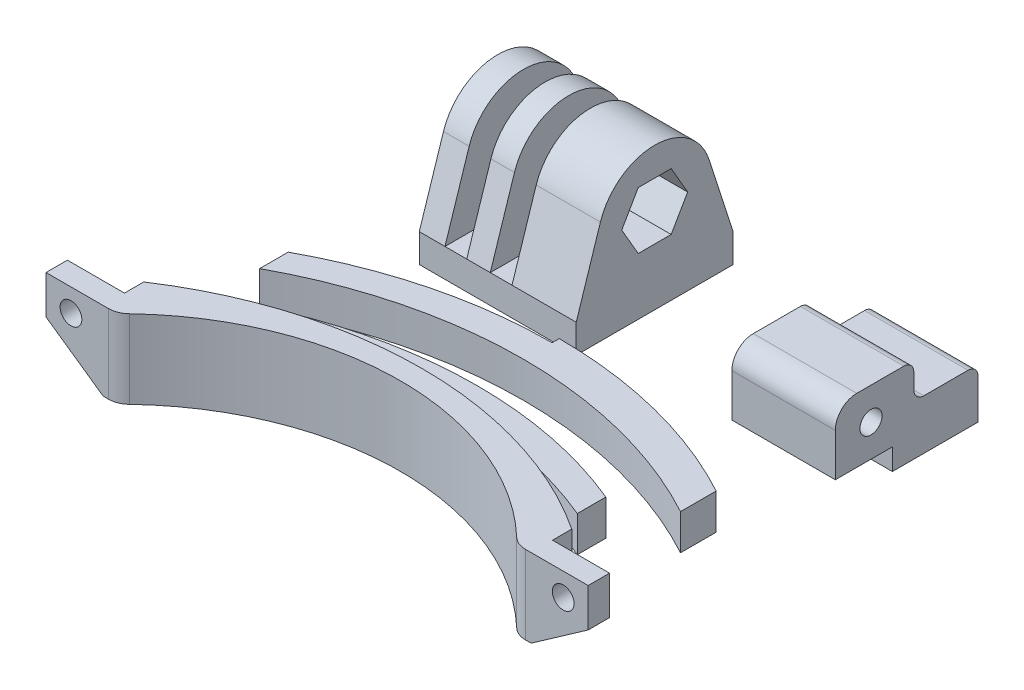
from build123d import *

# Parameters (mm, degrees)
BOSS_EXTRUDE1_DEPTH = 11
CUT_EXTRUDE1_REACH  = 16.7
SKETCH2_R           = 1.525
CUT_EXTRUDE12_REACH = 16.7
BOSS_EXTRUDE2_DEPTH = 5
CUT_EXTRUDE11_DEPTH = 5
BOSS_EXTRUDE3_DEPTH = 5
SKETCH10_W          = 14.5
SKETCH10_H          = 20
BOSS_EXTRUDE6_DEPTH = 12
SKETCH11_W          = 8
SKETCH11_H          = 3
CUT_EXTRUDE5_DEPTH  = 14.5
SKETCH12_R          = 1.55
CUT_EXTRUDE6_DEPTH  = 14.5
SKETCH13_W          = 22
SKETCH13_H          = 22
BOSS_EXTRUDE7_DEPTH = 4
SKETCH14_W          = 22
SKETCH14_H          = 18
SKETCH14_R          = 2.55
BOSS_EXTRUDE8_DEPTH = 22
CUT_EXTRUDE7_DEPTH  = 22
CUT_EXTRUDE8_START  = -20
SKETCH17_W          = 3.05
SKETCH17_H          = 22
CUT_EXTRUDE8_DEPTH  = 16
CUT_EXTRUDE9_DEPTH  = 7


with BuildPart() as part:
    # Sketch1 → Boss-Extrude1 (new body)
    with BuildSketch(Plane(origin=(0, 0, 0), x_dir=(1, 0, 0), z_dir=(0, 1, 0))):
        with BuildLine():
            Line((-30, 0), (-30, -2.7))
            Line((-30, -2.7), (-38, -2.7))
            Line((-38, -2.7), (-38, -5.7))
            Line((-38, -5.7), (-29.226700122, -5.7))
            ThreePointArc((-29.226700122, -5.7), (-28.111762502, -5.485123714), (-27.156540652, -4.87127607))
            ThreePointArc((-27.156540652, -4.87127607), (0, 6), (27.156540652, -4.87127607))
            ThreePointArc((27.156540652, -4.87127607), (28.111762502, -5.485123714), (29.226700122, -5.7))
            Line((29.226700122, -5.7), (38, -5.7))
            Line((38, -5.7), (38, -2.7))
            Line((38, -2.7), (30, -2.7))
            Line((30, -2.7), (30, 0))
            ThreePointArc((30, 0), (0, 9), (-30, 0))
        make_face()
    extrude(amount=BOSS_EXTRUDE1_DEPTH)

    # Sketch2 → Cut-Extrude1 (cut, up to next)
    with BuildSketch(Plane.XY.offset(5.7), mode=Mode.PRIVATE) as cut_extrude1_sk1:
        with Locations((-34.5, 7.8)):
            Circle(SKETCH2_R)
    cut_extrude1_tool1 = extrude(cut_extrude1_sk1.sketch, amount=-CUT_EXTRUDE1_REACH, mode=Mode.PRIVATE) & part.part
    add(cut_extrude1_tool1.solids().sort_by_distance((-34.5, 7.8, 5.7))[0], mode=Mode.SUBTRACT)
    # Sketch2 → Cut-Extrude1 (cut, up to next)
    with BuildSketch(Plane.XY.offset(5.7), mode=Mode.PRIVATE) as cut_extrude1_sk2:
        with Locations((34.5, 7.8)):
            Circle(SKETCH2_R)
    cut_extrude1_tool2 = extrude(cut_extrude1_sk2.sketch, amount=-CUT_EXTRUDE1_REACH, mode=Mode.PRIVATE) & part.part
    add(cut_extrude1_tool2.solids().sort_by_distance((34.5, 7.8, 5.7))[0], mode=Mode.SUBTRACT)

    # Sketch20 → Cut-Extrude12 (cut, up to next)
    with BuildSketch(Plane.XY.offset(5.7), mode=Mode.PRIVATE) as cut_extrude12_sk1:
        Polygon((-38, 5.6), (-30, 0), (-38, 0), align=None)
    cut_extrude12_tool1 = extrude(cut_extrude12_sk1.sketch, amount=-CUT_EXTRUDE12_REACH, mode=Mode.PRIVATE) & part.part
    add(cut_extrude12_tool1.solids().sort_by_distance((-35.333333, 1.866667, 5.7))[0], mode=Mode.SUBTRACT)
    # Sketch20 → Cut-Extrude12 (cut, up to next)
    with BuildSketch(Plane.XY.offset(5.7), mode=Mode.PRIVATE) as cut_extrude12_sk2:
        Polygon((38, 0), (30, 0), (38, 5.6), align=None)
    cut_extrude12_tool2 = extrude(cut_extrude12_sk2.sketch, amount=-CUT_EXTRUDE12_REACH, mode=Mode.PRIVATE) & part.part
    add(cut_extrude12_tool2.solids().sort_by_distance((35.333333, 1.866667, 5.7))[0], mode=Mode.SUBTRACT)


with BuildPart() as body_2:
    # Sketch3 → Boss-Extrude2 (new body)
    with BuildSketch(Plane(origin=(0, 0, 0), x_dir=(1, 0, 0), z_dir=(0, 1, 0))):
        with BuildLine():
            Line((-29.5, 8.785778647), (-29.5, 4.785778647))
            ThreePointArc((-29.5, 4.785778647), (0, 12.785778647), (29.5, 4.785778647))
            Line((29.5, 4.785778647), (29.5, 8.785778647))
            ThreePointArc((29.5, 8.785778647), (0, 16.785778647), (-29.5, 8.785778647))
        make_face()
    extrude(amount=BOSS_EXTRUDE2_DEPTH)

    # Sketch21 → Cut-Extrude11 (cut)
    with BuildSketch(Plane(origin=(0, 5, 0), x_dir=(1, 0, 0), z_dir=(0, 1, 0))):
        with BuildLine():
            ThreePointArc((-29.5, 4.785778647), (-26.058521382, 6.648560725), (-22.5, 8.276644791))
            Line((-22.5, 8.276644791), (-22.5, 12.276644791))
            ThreePointArc((-22.5, 12.276644791), (-26.058521382, 10.648560725), (-29.5, 8.785778647))
            Line((-29.5, 8.785778647), (-29.5, 4.785778647))
        make_face()
        with BuildLine():
            Line((22.5, 12.276644791), (22.5, 8.276644791))
            ThreePointArc((22.5, 8.276644791), (26.058521382, 6.648560725), (29.5, 4.785778647))
            Line((29.5, 4.785778647), (29.5, 8.785778647))
            ThreePointArc((29.5, 8.785778647), (26.058521382, 10.648560725), (22.5, 12.276644791))
        make_face()
    extrude(amount=-CUT_EXTRUDE11_DEPTH, mode=Mode.SUBTRACT)


with BuildPart() as body_3:
    # Sketch4 → Boss-Extrude3 (new body)
    with BuildSketch(Plane(origin=(0, 0, 0), x_dir=(1, 0, 0), z_dir=(0, 1, 0))):
        with BuildLine():
            Line((0, 28.244635791), (0, 27.244635791))
            ThreePointArc((0, 27.244635791), (-15.219231255, 25.340278728), (-29.5, 19.744635791))
            Line((-29.5, 19.744635791), (-29.5, 15.744635791))
            ThreePointArc((-29.5, 15.744635791), (0, 23.244635791), (29.5, 15.744635791))
            Line((29.5, 15.744635791), (29.5, 20.744635791))
            ThreePointArc((29.5, 20.744635791), (15.219231255, 26.340278728), (0, 28.244635791))
        make_face()
    extrude(amount=BOSS_EXTRUDE3_DEPTH)


with BuildPart() as body_4:
    # Sketch10 → Boss-Extrude6 (new body)
    with BuildSketch(Plane(origin=(0, 0, 0), x_dir=(1, 0, 0), z_dir=(0, 1, 0))):
        with Locations((27.239954972, 42.455194303)):
            Rectangle(SKETCH10_W, SKETCH10_H)
    extrude(amount=BOSS_EXTRUDE6_DEPTH)

    # Sketch11 → Cut-Extrude5 (cut)
    with BuildSketch(Plane(origin=(34.489954972, 0, 0), x_dir=(0, 0, -1), z_dir=(1, 0, 0))):
        with Locations((36.455194303, 1.5)):
            Rectangle(SKETCH11_W, SKETCH11_H)
        with BuildLine():
            Line((32.455194303, 12), (32.455194303, 9))
            ThreePointArc((32.455194303, 9), (33.333873959, 11.121320344), (35.455194303, 12))
            Line((35.455194303, 12), (32.455194303, 12))
        make_face()
        with BuildLine():
            Line((52.455194303, 12), (42.055194303, 12))
            ThreePointArc((42.055194303, 12), (43.045143797, 11.589949494), (43.455194303, 10.6))
            Line((43.455194303, 10.6), (43.455194303, 8.4))
            ThreePointArc((43.455194303, 8.4), (43.865244809, 7.410050506), (44.855194303, 7))
            Line((44.855194303, 7), (51.055194303, 7))
            ThreePointArc((51.055194303, 7), (52.045143797, 6.589949494), (52.455194303, 5.6))
            Line((52.455194303, 5.6), (52.455194303, 7))
            Line((52.455194303, 7), (52.455194303, 12))
        make_face()
    extrude(amount=-CUT_EXTRUDE5_DEPTH, mode=Mode.SUBTRACT)

    # Sketch12 → Cut-Extrude6 (cut)
    with BuildSketch(Plane(origin=(34.489954972, 0, 0), x_dir=(0, 0, -1), z_dir=(1, 0, 0))):
        with Locations((37.455194303, 7.5)):
            Circle(SKETCH12_R)
    extrude(amount=-CUT_EXTRUDE6_DEPTH, mode=Mode.SUBTRACT)


with BuildPart() as body_5:
    # Sketch13 → Boss-Extrude7 (new body)
    with BuildSketch(Plane(origin=(28.711110342, 0, 0), x_dir=(1, 0, 0), z_dir=(0, 1, 0))):
        with Locations((-41.507760914, 43.422583893)):
            Rectangle(SKETCH13_W, SKETCH13_H)
    extrude(amount=BOSS_EXTRUDE7_DEPTH)

    # Sketch14 → Boss-Extrude8 (add)
    with BuildSketch(Plane(origin=(-1.796650572, 0, 0), x_dir=(0, 0, -1), z_dir=(1, 0, 0))):
        with Locations((43.422583893, 13)):
            Rectangle(SKETCH14_W, SKETCH14_H)
        with Locations((43.422583893, 12)):
            Circle(SKETCH14_R, mode=Mode.SUBTRACT)
    extrude(amount=-BOSS_EXTRUDE8_DEPTH)

    # Sketch15 → Cut-Extrude7 (cut)
    with BuildSketch(Plane(origin=(-1.796650572, 0, 0), x_dir=(0, 0, -1), z_dir=(1, 0, 0))):
        with BuildLine():
            Line((32.422583893, 4), (35.811773083, 14.464864865))
            ThreePointArc((35.811773083, 14.464864865), (43.422583893, 20), (51.033394704, 14.464864865))
            Line((51.033394704, 14.464864865), (54.422583893, 4))
            Line((54.422583893, 4), (54.422583893, 22))
            Line((54.422583893, 22), (32.422583893, 22))
            Line((32.422583893, 22), (32.422583893, 4))
        make_face()
    extrude(amount=-CUT_EXTRUDE7_DEPTH, mode=Mode.SUBTRACT)

    # Sketch17 → Cut-Extrude8 (cut)
    with BuildSketch(Plane(origin=(28.711110342, 0, 0), x_dir=(1, 0, 0), z_dir=(0, -1, 0)).offset(CUT_EXTRUDE8_START)):
        with Locations((-47.382760914, -43.422583893)):
            Rectangle(SKETCH17_W, SKETCH17_H)
        with Locations((-41.032760914, -43.422583893)):
            Rectangle(SKETCH17_W, SKETCH17_H)
    extrude(amount=CUT_EXTRUDE8_DEPTH, mode=Mode.SUBTRACT)

    # Sketch16 → Cut-Extrude9 (cut)
    with BuildSketch(Plane(origin=(-1.796650572, 0, 0), x_dir=(0, 0, -1), z_dir=(1, 0, 0))):
        Polygon((45.73198497, 16), (41.113182817, 16), (38.80378174, 12), (41.113182817, 8), (45.73198497, 8), (48.041386047, 12), align=None)
    extrude(amount=-CUT_EXTRUDE9_DEPTH, mode=Mode.SUBTRACT)


solid = Compound([part.part, body_2.part, body_3.part, body_4.part, body_5.part])
